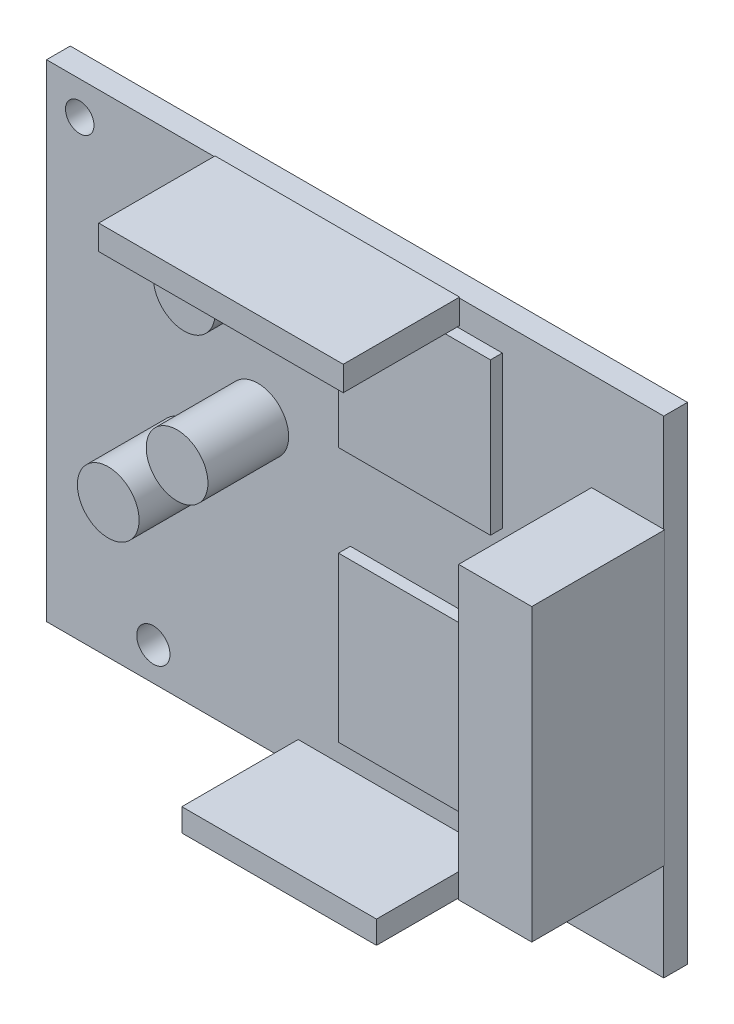
from build123d import *

# Parameters (mm, degrees)
SKETCH1_R            = 3.25
BOSS_EXTRUDE1_DEPTH  = 8.5
SKETCH3_W            = 65
SKETCH3_H            = 51.25
BOSS_EXTRUDE2_DEPTH  = 2.5
SKETCH4_W            = 7.6
SKETCH4_H            = 30.6
BOSS_EXTRUDE3_DEPTH  = 14
SKETCH5_R            = 3.25
BOSS_EXTRUDE4_DEPTH  = 8.5
SKETCH6_W            = 25.75
SKETCH6_H            = 2.5
BOSS_EXTRUDE5_DEPTH  = 12.25
SKETCH8_R            = 3.25
BOSS_EXTRUDE9_DEPTH  = 8.5
SKETCH9_W            = 20.5
SKETCH9_H            = 2.5
BOSS_EXTRUDE10_DEPTH = 12.25
SKETCH10_W           = 20.5
SKETCH10_H           = 12.25
CUT_EXTRUDE1_DEPTH   = 0.1
SKETCH12_W           = 25.75
SKETCH12_H           = 12.25
BOSS_EXTRUDE11_DEPTH = 0.1
SKETCH14_W           = 14
SKETCH14_H           = 30.6
BOSS_EXTRUDE12_DEPTH = 0.1
SKETCH15_R           = 1.5
CUT_EXTRUDE2_DEPTH   = 3.5
SKETCH16_R           = 1.75
CUT_EXTRUDE3_DEPTH   = 3.5
SKETCH17_W           = 16
SKETCH17_H           = 16
BOSS_EXTRUDE13_DEPTH = 1.25
SKETCH18_W           = 16
SKETCH18_H           = 17.25
BOSS_EXTRUDE14_DEPTH = 1.25


with BuildPart() as part:
    # Sketch1 → Boss-Extrude1 (new body)
    with BuildSketch(Plane.XY):
        with Locations((-17.5, -3)):
            Circle(SKETCH1_R)
    extrude(amount=BOSS_EXTRUDE1_DEPTH)

    # Sketch3 → Boss-Extrude2 (add)
    with BuildSketch(Plane.XY):
        Rectangle(SKETCH3_W, SKETCH3_H)
    extrude(amount=-BOSS_EXTRUDE2_DEPTH)

    # Sketch4 → Boss-Extrude3 (add)
    with BuildSketch(Plane.XY):
        with Locations((28.7, 0)):
            Rectangle(SKETCH4_W, SKETCH4_H)
    extrude(amount=BOSS_EXTRUDE3_DEPTH)

    # Sketch5 → Boss-Extrude4 (add)
    with BuildSketch(Plane.XY):
        with Locations((-10.25, 4)):
            Circle(SKETCH5_R)
    extrude(amount=BOSS_EXTRUDE4_DEPTH)

    # Sketch6 → Boss-Extrude5 (add)
    with BuildSketch(Plane.XY):
        with Locations((-1.875, 24.375)):
            Rectangle(SKETCH6_W, SKETCH6_H)
    extrude(amount=BOSS_EXTRUDE5_DEPTH)

    # Sketch8 → Boss-Extrude9 (add)
    with BuildSketch(Plane.XY):
        with Locations((-9.5, 19.87)):
            Circle(SKETCH8_R)
    extrude(amount=BOSS_EXTRUDE9_DEPTH)

    # Sketch9 → Boss-Extrude10 (add)
    with BuildSketch(Plane.XY):
        with Locations((4.25, -24.375)):
            Rectangle(SKETCH9_W, SKETCH9_H)
    extrude(amount=BOSS_EXTRUDE10_DEPTH)

    # Sketch10 → Cut-Extrude1 (cut)
    with BuildSketch(Plane.XZ.offset(25.625)):
        with Locations((4.25, 6.125)):
            Rectangle(SKETCH10_W, SKETCH10_H)
    extrude(amount=-CUT_EXTRUDE1_DEPTH, mode=Mode.SUBTRACT)

    # Sketch12 → Boss-Extrude11 (add)
    with BuildSketch(Plane(origin=(0, 25.625, 0), x_dir=(1, 0, 0), z_dir=(0, 1, 0))):
        with Locations((-1.875, -6.125)):
            Rectangle(SKETCH12_W, SKETCH12_H)
    extrude(amount=BOSS_EXTRUDE11_DEPTH)

    # Sketch14 → Boss-Extrude12 (add)
    with BuildSketch(Plane(origin=(32.5, 0, 0), x_dir=(0, 0, -1), z_dir=(1, 0, 0))):
        with Locations((-7, 0)):
            Rectangle(SKETCH14_W, SKETCH14_H)
    extrude(amount=BOSS_EXTRUDE12_DEPTH)

    # Sketch15 → Cut-Extrude2 (cut, through all)
    with BuildSketch(Plane.XY):
        with Locations((-29, 22.125)):
            Circle(SKETCH15_R)
    extrude(amount=-CUT_EXTRUDE2_DEPTH, mode=Mode.SUBTRACT)

    # Sketch16 → Cut-Extrude3 (cut, through all)
    with BuildSketch(Plane.XY):
        with Locations((-21.25, -22.125)):
            Circle(SKETCH16_R)
    extrude(amount=-CUT_EXTRUDE3_DEPTH, mode=Mode.SUBTRACT)

    # Sketch17 → Boss-Extrude13 (add)
    with BuildSketch(Plane.XY):
        with Locations((7.5, 14.875)):
            Rectangle(SKETCH17_W, SKETCH17_H)
    extrude(amount=BOSS_EXTRUDE13_DEPTH)

    # Sketch18 → Boss-Extrude14 (add)
    with BuildSketch(Plane.XY):
        with Locations((7.5, -11.375)):
            Rectangle(SKETCH18_W, SKETCH18_H)
    extrude(amount=BOSS_EXTRUDE14_DEPTH)


solid = part.part
